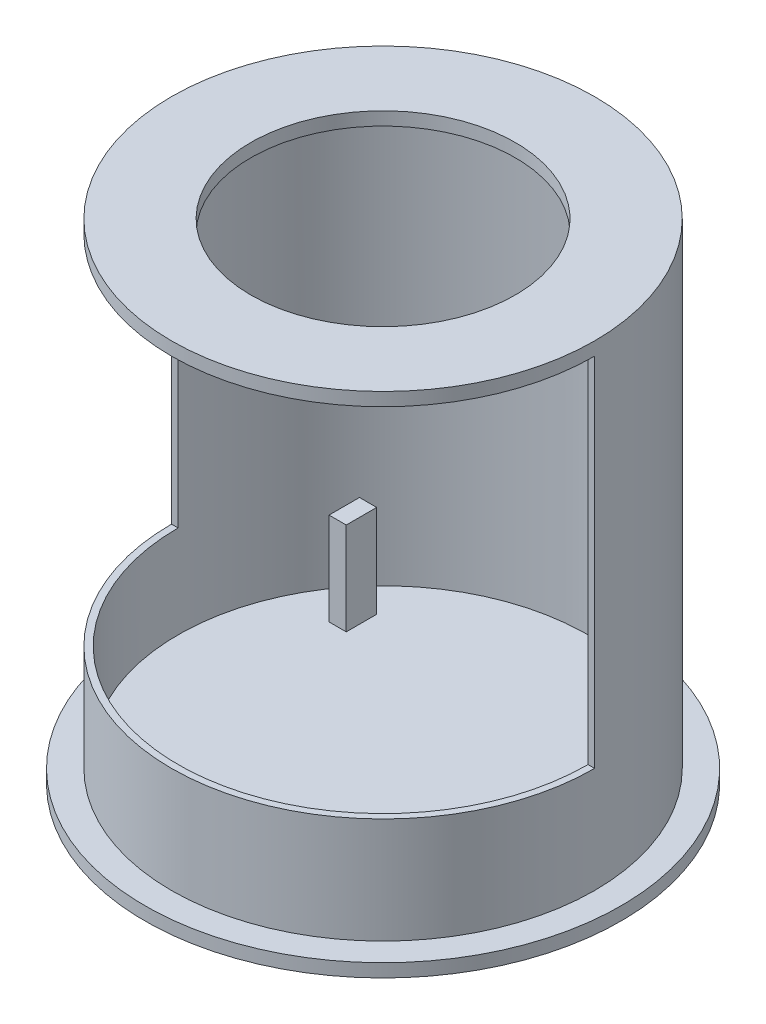
from build123d import *
from build123d.topology import SkipClean

# Parameters (mm, degrees)
BOSS_EXTRU_1_DEPTH      = 5
BOSS_EXTRU_2_DEPTH      = 180
BOSS_EXTRU_3_DEPTH      = 5
ENL_V_MAT_EXTRU_1_DEPTH = 5
BOSS_EXTRU_4_DEPTH      = 40
BOSS_EXTRU_5_DEPTH      = 5
ESQUISSE8_R             = 90
BOSS_EXTRU_6_DEPTH      = 5
BOSS_EXTRU_7_DEPTH      = 5
BOSS_EXTRU_8_DEPTH      = 5
ESQUISSE12_W            = 6.5
ESQUISSE12_H            = 11.508229801
ESQUISSE12_H_2          = 11.51
BOSS_EXTRU_9_DEPTH      = 35


with BuildPart() as part:
    # Esquisse1 → Boss.-Extru.1 (new body)
    with BuildSketch(Plane(origin=(0, 0, 0), x_dir=(1, 0, 0), z_dir=(0, 1, 0))):
        with BuildLine():
            ThreePointArc((0, 77.5), (-54.800775542, 54.800775542), (-77.5, 0))
            Line((-77.5, 0), (0, 0))
            Line((0, 0), (77.5, 0))
            ThreePointArc((77.5, 0), (54.800775542, 54.800775542), (0, 77.5))
        make_face()
    extrude(amount=BOSS_EXTRU_1_DEPTH)

    # Esquisse2 → Boss.-Extru.2 (add)
    with BuildSketch(Plane.XZ):
        with BuildLine():
            Line((80, 0), (77.5, 0))
            ThreePointArc((77.5, 0), (0, -77.5), (-77.5, 0))
            Line((-77.5, 0), (-80, 0))
            ThreePointArc((-80, 0), (0, -80), (80, 0))
        make_face()
    extrude(amount=-BOSS_EXTRU_2_DEPTH)

    # Esquisse4 → Boss.-Extru.3 (add)
    with BuildSketch(Plane(origin=(0, 180, 0), x_dir=(1, 0, 0), z_dir=(0, 1, 0))):
        with BuildLine():
            Line((-77.5, 0), (77.5, 0))
            ThreePointArc((77.5, 0), (0, 77.5), (-77.5, 0))
        make_face()
    extrude(amount=-BOSS_EXTRU_3_DEPTH)

    # Esquisse5 → Enlèv. mat.-Extru.1 (cut)
    with BuildSketch(Plane(origin=(0, 180, 0), x_dir=(1, 0, 0), z_dir=(0, 1, 0))):
        with BuildLine():
            Line((-50, 0), (50, 0))
            ThreePointArc((50, 0), (0, 50), (-50, 0))
        make_face()
    extrude(amount=-ENL_V_MAT_EXTRU_1_DEPTH, mode=Mode.SUBTRACT)

    # Esquisse6 → Boss.-Extru.4 (add)
    with SkipClean():  # the faces are left unmerged after this step: merging them gives an invalid solid
        with BuildSketch(Plane(origin=(0, 0, 0), x_dir=(1, 0, 0), z_dir=(0, 1, 0))):
            with BuildLine():
                Line((80, 0), (77.5, 0))
                ThreePointArc((77.5, 0), (0, -77.5), (-77.5, 0))
                Line((-77.5, 0), (-80, 0))
                ThreePointArc((-80, 0), (0, -80), (80, 0))
            make_face()
        extrude(amount=BOSS_EXTRU_4_DEPTH)

    # Esquisse7 → Boss.-Extru.5 (add)
    with BuildSketch(Plane(origin=(0, 0, 0), x_dir=(1, 0, 0), z_dir=(0, 1, 0))):
        with BuildLine():
            Line((0, 0), (-77.5, 0))
            ThreePointArc((-77.5, 0), (0, -77.5), (77.5, 0))
            Line((77.5, 0), (0, 0))
        make_face()
    extrude(amount=BOSS_EXTRU_5_DEPTH)

    # Esquisse8 → Boss.-Extru.6 (add)
    with BuildSketch(Plane.XZ):
        with Locations(Location((0, 0, 0), (0, 0, 270))):
            Circle(ESQUISSE8_R)
    extrude(amount=BOSS_EXTRU_6_DEPTH)



with BuildPart() as body_2:
    # Esquisse9 → Boss.-Extru.7 (new body)
    with BuildSketch(Plane(origin=(0, 180, 0), x_dir=(1, 0, 0), z_dir=(0, 1, 0))):
        with BuildLine():
            Line((80, 0), (77.5, 0))
            ThreePointArc((77.5, 0), (0, -77.5), (-77.5, 0))
            Line((-77.5, 0), (-80, 0))
            ThreePointArc((-80, 0), (0, -80), (80, 0))
        make_face()
    extrude(amount=-BOSS_EXTRU_7_DEPTH)


with BuildPart() as part_1:
    add(part.part)

    add(body_2.part)  # Boss.-Extru.8 merges body 2
    # Esquisse10 → Boss.-Extru.8 (add)
    with BuildSketch(Plane(origin=(0, 180, 0), x_dir=(1, 0, 0), z_dir=(0, 1, 0))):
        with BuildLine():
            ThreePointArc((-77.5, 0), (0, -77.5), (77.5, 0))
            Line((77.5, 0), (50, 0))
            ThreePointArc((50, 0), (0, -50), (-50, 0))
            Line((-50, 0), (-77.5, 0))
        make_face()
    extrude(amount=-BOSS_EXTRU_8_DEPTH)

    # Esquisse12 → Boss.-Extru.9 (add)
    with BuildSketch(Plane(origin=(0, 5, 0), x_dir=(1, 0, 0), z_dir=(0, 1, 0))):
        with Locations((-49.92, 38.5041149)):
            Rectangle(ESQUISSE12_W, ESQUISSE12_H)
        with Locations((49.92, 38.505)):
            Rectangle(ESQUISSE12_W, ESQUISSE12_H_2)
    extrude(amount=BOSS_EXTRU_9_DEPTH)


solid = part_1.part
